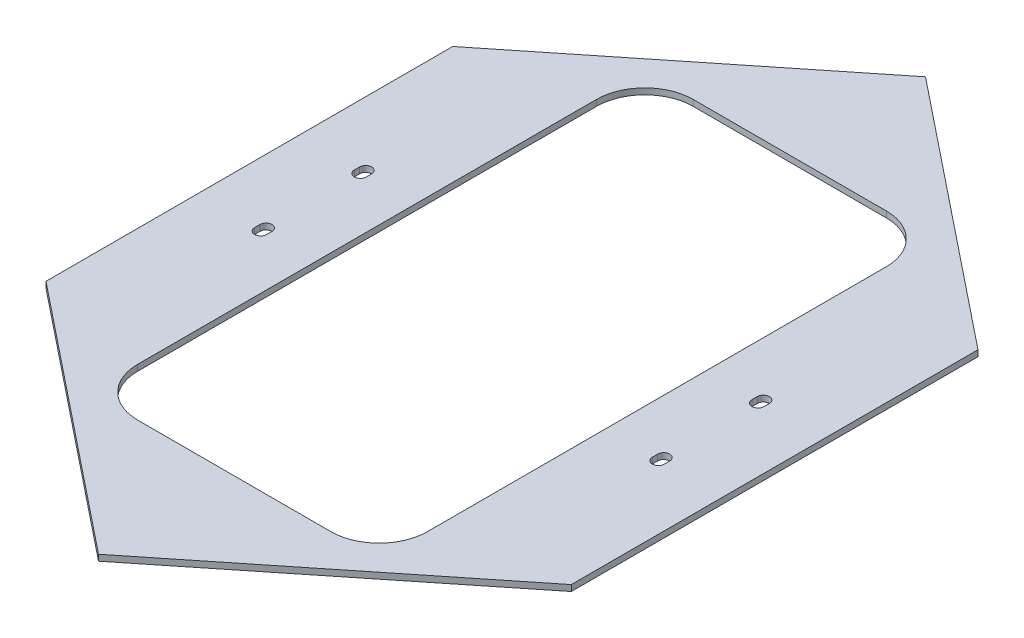
from build123d import *

# Parameters (mm, degrees)
BOSS_EXTRUDE1_DEPTH = 3.175


with BuildPart() as part:
    # Sketch1 → Boss-Extrude1 (new body, symmetric)
    with BuildSketch(Plane(origin=(0, 0, 0), x_dir=(1, 0, 0), z_dir=(0, 1, 0))):
        Polygon((-276.225, 213.881843), (0, 434.861843), (276.225, 213.881843), (276.225, -213.881843), (0, -434.861843), (-276.225, -213.881843), align=None)
        with BuildLine():
            Line((101.6, -292.1), (-101.6, -292.1))
            ThreePointArc((-101.6, -292.1), (-137.521024484, -277.221024484), (-152.4, -241.3))
            Line((-152.4, -241.3), (-152.4, 241.3))
            ThreePointArc((-152.4, 241.3), (-137.521024484, 277.221024484), (-101.6, 292.1))
            Line((-101.6, 292.1), (101.6, 292.1))
            ThreePointArc((101.6, 292.1), (137.521024484, 277.221024484), (152.4, 241.3))
            Line((152.4, 241.3), (152.4, -241.3))
            ThreePointArc((152.4, -241.3), (137.521024484, -277.221024484), (101.6, -292.1))
        make_face(mode=Mode.SUBTRACT)
        with BuildLine():
            Line((-202.803125, 55.165625), (-202.803125, 49.609375))
            ThreePointArc((-202.803125, 49.609375), (-209.153125, 43.259375), (-215.503125, 49.609375))
            Line((-215.503125, 49.609375), (-215.503125, 55.165625))
            ThreePointArc((-215.503125, 55.165625), (-209.153125, 61.515625), (-202.803125, 55.165625))
        make_face(mode=Mode.SUBTRACT)
        with BuildLine():
            Line((-202.803125, -55.165625), (-202.803125, -49.609375))
            ThreePointArc((-202.803125, -49.609375), (-209.153125, -43.259375), (-215.503125, -49.609375))
            Line((-215.503125, -49.609375), (-215.503125, -55.165625))
            ThreePointArc((-215.503125, -55.165625), (-209.153125, -61.515625), (-202.803125, -55.165625))
        make_face(mode=Mode.SUBTRACT)
        with BuildLine():
            Line((202.803125, -55.165625), (202.803125, -49.609375))
            ThreePointArc((202.803125, -49.609375), (209.153125, -43.259375), (215.503125, -49.609375))
            Line((215.503125, -49.609375), (215.503125, -55.165625))
            ThreePointArc((215.503125, -55.165625), (209.153125, -61.515625), (202.803125, -55.165625))
        make_face(mode=Mode.SUBTRACT)
        with BuildLine():
            Line((202.803125, 55.165625), (202.803125, 49.609375))
            ThreePointArc((202.803125, 49.609375), (209.153125, 43.259375), (215.503125, 49.609375))
            Line((215.503125, 49.609375), (215.503125, 55.165625))
            ThreePointArc((215.503125, 55.165625), (209.153125, 61.515625), (202.803125, 55.165625))
        make_face(mode=Mode.SUBTRACT)
    extrude(amount=BOSS_EXTRUDE1_DEPTH, both=True)


solid = part.part
